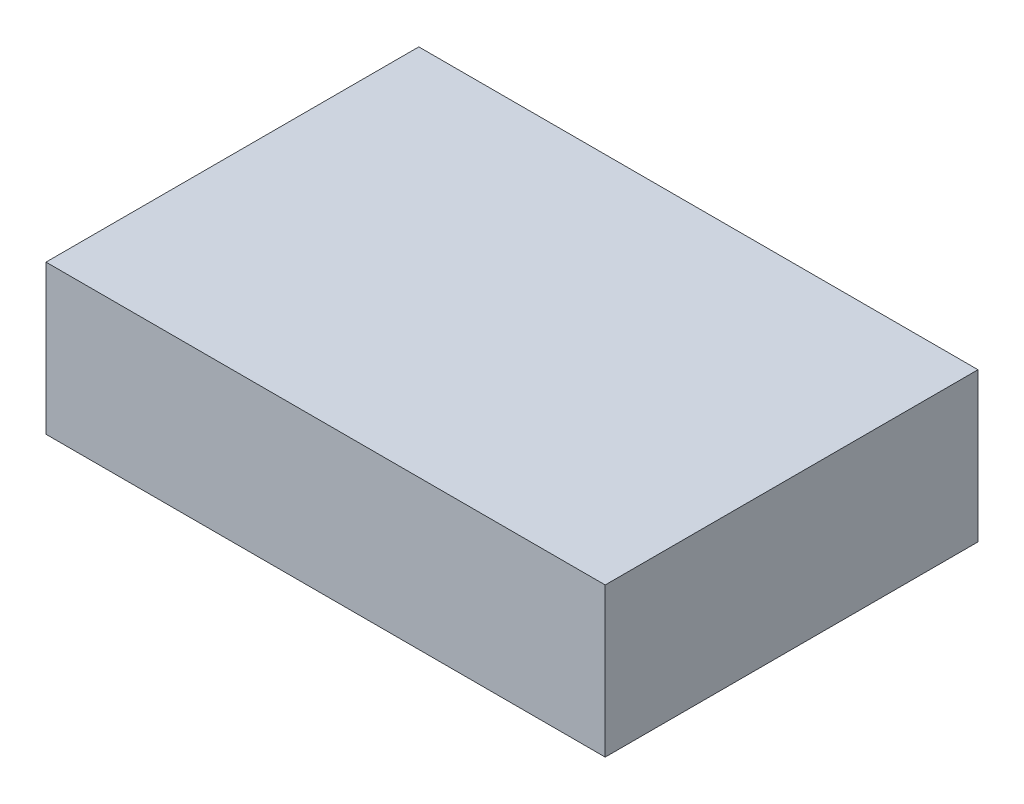
from build123d import *

# Parameters (mm, degrees)
SKETCH1_W           = 150
SKETCH1_H           = 100
BOSS_EXTRUDE1_DEPTH = 40


with BuildPart() as part:
    # Sketch1 → Boss-Extrude1 (new body)
    with BuildSketch(Plane(origin=(0, 0, 0), x_dir=(1, 0, 0), z_dir=(0, 1, 0))):
        with Locations((-27.842222947, -0.507614213)):
            Rectangle(SKETCH1_W, SKETCH1_H)
    extrude(amount=BOSS_EXTRUDE1_DEPTH)


solid = part.part
